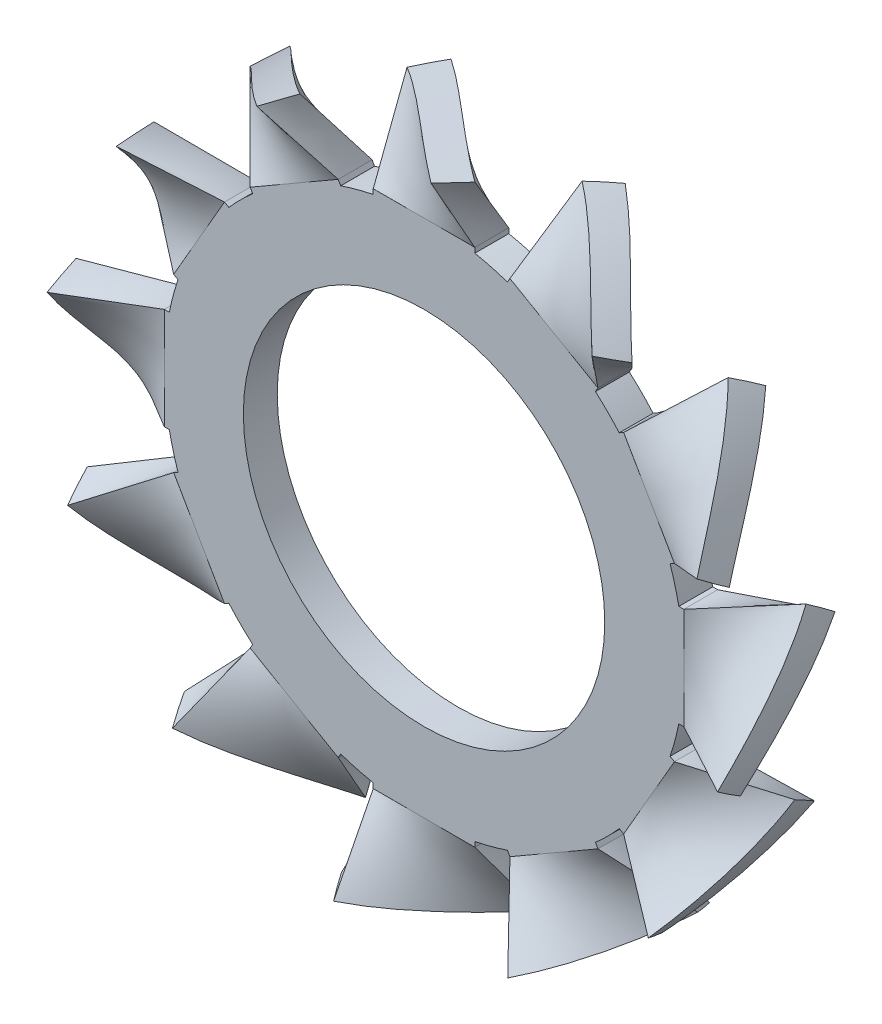
from build123d import *

# Parameters (mm, degrees)
SKETCH2_W               = 0.9
SKETCH2_H               = 0.3
SKETCH4_W               = 0.9
SKETCH4_H               = 0.3
EXTRUDE1_DEPTH          = 0.7
CIRPATTERN1_COUNT       = 12
SKETCH5_R               = 2.3
SKETCH5_R_2             = 1.6
EXTRUDE2_DEPTH          = 0.15
EXTRUDE2_DEPTH_BACK     = 0.15
SKETCH6_OUTSIDE_W       = 9.71
SKETCH6_OUTSIDE_H       = 9.71
SKETCH6_OUTSIDE_R       = 3
CUT_EXTRUDE1_DEPTH      = 1.537297736
CUT_EXTRUDE1_DEPTH_BACK = 1.537297736


with BuildPart() as part:
    # Sketch3 → Loft1 section 0
    with BuildSketch(Plane(origin=(0, 3, 0), x_dir=(-1, 0, 0), z_dir=(0, 1, 0))):
        Polygon((0.603856326, -0.330465637), (0.430303672, -0.537297636), (-0.603856326, 0.330465637), (-0.430303672, 0.537297636), align=None)
    # Sketch2 → Loft1 section 1
    with BuildSketch(Plane(origin=(0, 2.3, 0), x_dir=(-1, 0, 0), z_dir=(0, 1, 0))):
        Rectangle(SKETCH2_W, SKETCH2_H)
    loft()

    # Sketch4 → Extrude1 (add)
    with BuildSketch(Plane.XZ.offset(-2.3)):
        Rectangle(SKETCH4_W, SKETCH4_H)
    extrude(amount=EXTRUDE1_DEPTH)


with BuildPart() as cirpattern1_1:
    # CirPattern1: pattern copy
    add(part.part.rotate(Axis((0, 0, -0.572098055), (0, 0, 1)), 1 * 360 / CIRPATTERN1_COUNT))


with BuildPart() as cirpattern1_2:
    # CirPattern1: pattern copy
    add(part.part.rotate(Axis((0, 0, -0.572098055), (0, 0, 1)), 2 * 360 / CIRPATTERN1_COUNT))


with BuildPart() as cirpattern1_3:
    # CirPattern1: pattern copy
    add(part.part.rotate(Axis((0, 0, -0.572098055), (0, 0, 1)), 3 * 360 / CIRPATTERN1_COUNT))


with BuildPart() as cirpattern1_4:
    # CirPattern1: pattern copy
    add(part.part.rotate(Axis((0, 0, -0.572098055), (0, 0, 1)), 4 * 360 / CIRPATTERN1_COUNT))


with BuildPart() as cirpattern1_5:
    # CirPattern1: pattern copy
    add(part.part.rotate(Axis((0, 0, -0.572098055), (0, 0, 1)), 5 * 360 / CIRPATTERN1_COUNT))


with BuildPart() as cirpattern1_6:
    # CirPattern1: pattern copy
    add(part.part.rotate(Axis((0, 0, -0.572098055), (0, 0, 1)), 6 * 360 / CIRPATTERN1_COUNT))


with BuildPart() as cirpattern1_7:
    # CirPattern1: pattern copy
    add(part.part.rotate(Axis((0, 0, -0.572098055), (0, 0, 1)), 7 * 360 / CIRPATTERN1_COUNT))


with BuildPart() as cirpattern1_8:
    # CirPattern1: pattern copy
    add(part.part.rotate(Axis((0, 0, -0.572098055), (0, 0, 1)), 8 * 360 / CIRPATTERN1_COUNT))


with BuildPart() as cirpattern1_9:
    # CirPattern1: pattern copy
    add(part.part.rotate(Axis((0, 0, -0.572098055), (0, 0, 1)), 9 * 360 / CIRPATTERN1_COUNT))


with BuildPart() as cirpattern1_10:
    # CirPattern1: pattern copy
    add(part.part.rotate(Axis((0, 0, -0.572098055), (0, 0, 1)), 10 * 360 / CIRPATTERN1_COUNT))


with BuildPart() as cirpattern1_11:
    # CirPattern1: pattern copy
    add(part.part.rotate(Axis((0, 0, -0.572098055), (0, 0, 1)), 11 * 360 / CIRPATTERN1_COUNT))


with BuildPart() as part_1:
    add(part.part)

    add(cirpattern1_1.part)  # Extrude2 merges CirPattern1_1

    add(cirpattern1_2.part)  # Extrude2 merges CirPattern1_2

    add(cirpattern1_3.part)  # Extrude2 merges CirPattern1_3

    add(cirpattern1_4.part)  # Extrude2 merges CirPattern1_4

    add(cirpattern1_5.part)  # Extrude2 merges CirPattern1_5

    add(cirpattern1_6.part)  # Extrude2 merges CirPattern1_6

    add(cirpattern1_7.part)  # Extrude2 merges CirPattern1_7

    add(cirpattern1_8.part)  # Extrude2 merges CirPattern1_8

    add(cirpattern1_9.part)  # Extrude2 merges CirPattern1_9

    add(cirpattern1_10.part)  # Extrude2 merges CirPattern1_10

    add(cirpattern1_11.part)  # Extrude2 merges CirPattern1_11
    # Sketch5 → Extrude2 (add, two sides)
    with BuildSketch(Plane.XY) as extrude2_sk:
        Circle(SKETCH5_R)
        Circle(SKETCH5_R_2, mode=Mode.SUBTRACT)
    extrude(amount=EXTRUDE2_DEPTH)
    extrude(extrude2_sk.sketch, amount=-EXTRUDE2_DEPTH_BACK)

    # Sketch6 outside → Cut-Extrude1 (cut, two sides)
    with BuildSketch(Plane.XY) as cut_extrude1_sk:
        Rectangle(SKETCH6_OUTSIDE_W, SKETCH6_OUTSIDE_H)
        Circle(SKETCH6_OUTSIDE_R, mode=Mode.SUBTRACT)
    extrude(amount=CUT_EXTRUDE1_DEPTH, mode=Mode.SUBTRACT)
    extrude(cut_extrude1_sk.sketch, amount=-CUT_EXTRUDE1_DEPTH_BACK, mode=Mode.SUBTRACT)


solid = part_1.part
